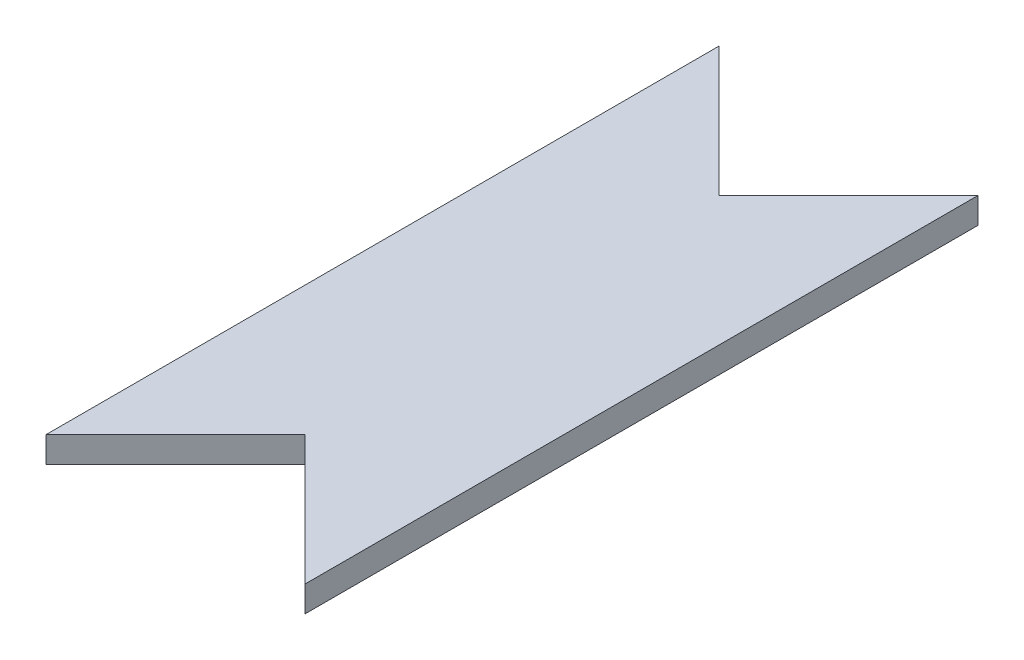
from build123d import *

# Parameters (mm, degrees)
BOSS_EXTRUDE1_DEPTH = 1.27


with BuildPart() as part:
    # Sketch1 → Boss-Extrude1 (new body)
    with BuildSketch(Plane(origin=(0, 0, 0), x_dir=(1, 0, 0), z_dir=(0, 1, 0))):
        Polygon((3.814197139, -10.799197139), (-2.535802861, -17.149197139), (-2.535802861, 15.870802861), (3.814197139, 9.520802861), (10.164197139, 15.870802861), (10.164197139, -17.149197139), align=None)
    extrude(amount=BOSS_EXTRUDE1_DEPTH)


solid = part.part
